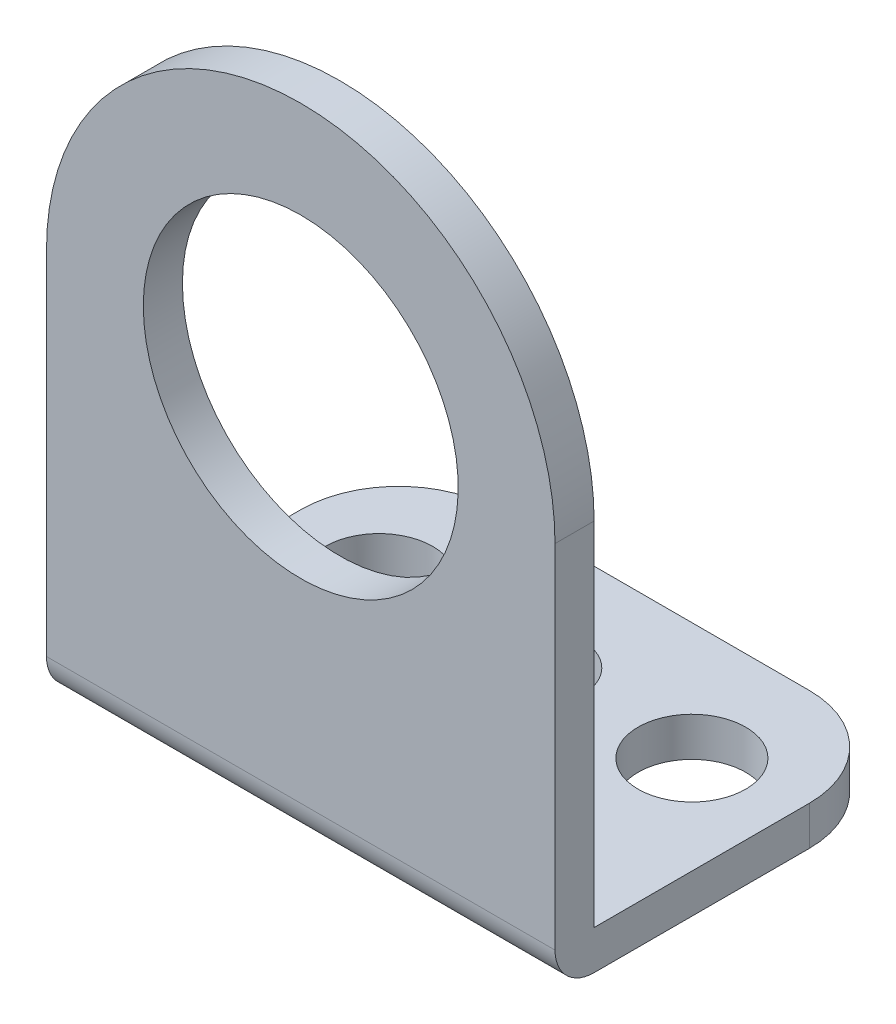
from build123d import *

# Parameters (mm, degrees)
BOSS_EXTRUDE1_DEPTH = 13
SKETCH12_R          = 8.05
BOSS_EXTRUDE2_DEPTH = 2
FILLET3_R           = 2
SKETCH15_R          = 2.4
SKETCH15_R_2        = 2.75
CUT_EXTRUDE1_DEPTH  = 2
FILLET4_R           = 5
RIB1_REACH          = 43.255
SKETCH17_WALL_W     = 91.58167319
SKETCH17_WALL_H     = 2
RIB1_DRAFT_ANGLE    = 30
RIB2_REACH          = 43.255
SKETCH18_WALL_W     = 91.58167319
SKETCH18_WALL_H     = 2
RIB2_DRAFT_ANGLE    = 30


with BuildPart() as part:
    # Sketch1 → Boss-Extrude1 (new, symmetric)
    with BuildSketch(Plane(origin=(0, 0, 0), x_dir=(0, 0, -1), z_dir=(1, 0, 0))):
        Polygon((0, 7.5), (2, 7.5), (2, 2), (18, 2), (18, 0), (0, 0), align=None)
    extrude(amount=BOSS_EXTRUDE1_DEPTH, both=True)

    # Sketch12 → Boss-Extrude2 (add)
    with BuildSketch(Plane(origin=(0, 0, -2), x_dir=(-1, 0, 0), z_dir=(0, 0, -1))):
        with BuildLine():
            Line((13, 20), (13, 7.5))
            Line((13, 7.5), (-13, 7.5))
            Line((-13, 7.5), (-13, 20))
            ThreePointArc((-13, 20), (0, 33), (13, 20))
        make_face()
        with Locations((0, 20)):
            Circle(SKETCH12_R, mode=Mode.SUBTRACT)
    extrude(amount=-BOSS_EXTRUDE2_DEPTH)

    # Fillet3
    fillet3_edges = [part.edges().sort_by_distance(p)[0] for p in [
        (0, 0, 0),
    ]]
    fillet(fillet3_edges, radius=FILLET3_R)

    # Sketch15 → Cut-Extrude1 (cut)
    with BuildSketch(Plane(origin=(0, 2, 0), x_dir=(1, 0, 0), z_dir=(0, 1, 0))):
        with Locations(Location((0, 12, 0), (0, 0, 270))):
            Circle(SKETCH15_R)
        with Locations(Location((8, 12, 0), (0, 0, 270))):
            Circle(SKETCH15_R_2)
        with Locations(Location((-8, 12, 0), (0, 0, 270))):
            Circle(SKETCH15_R_2)
    extrude(amount=-CUT_EXTRUDE1_DEPTH, mode=Mode.SUBTRACT)

    # Fillet4
    fillet4_edges = [part.edges().sort_by_distance(p)[0] for p in [
        (13, 1, -18),
        (-13, 1, -18),
    ]]
    fillet(fillet4_edges, radius=FILLET4_R)

    # Sketch17 wall → Rib1 (add, up to next)
    with BuildSketch(Plane(origin=(4, 4.5, -4.5), x_dir=(0, -0.707106781187, -0.707106781187), z_dir=(0, 0.707106781187, -0.707106781187)), mode=Mode.PRIVATE) as rib1_sk1:
        Rectangle(SKETCH17_WALL_W, SKETCH17_WALL_H)
    rib1_tool1 = extrude(rib1_sk1.sketch, amount=-RIB1_REACH, mode=Mode.PRIVATE) - part.part
    add(rib1_tool1.solids().sort_by_distance((4, 4.5, -4.5))[0])

    # Rib1 draft
    rib1_draft_faces = [part.faces().sort_by_distance(p)[0] for p in [
        (3, 4.146446609, -4.146446609),
        (5, 4.146446609, -4.146446609),
    ]]
    draft(rib1_draft_faces, Plane(origin=(4, 4.5, -4.5), x_dir=(0, -0.707106781187, -0.707106781187), z_dir=(0, 0.707106781187, -0.707106781187)), RIB1_DRAFT_ANGLE)

    # Sketch18 wall → Rib2 (add, up to next)
    with BuildSketch(Plane(origin=(-4, 4.5, -4.5), x_dir=(0, -0.707106781187, -0.707106781187), z_dir=(0, 0.707106781187, -0.707106781187)), mode=Mode.PRIVATE) as rib2_sk1:
        Rectangle(SKETCH18_WALL_W, SKETCH18_WALL_H)
    rib2_tool1 = extrude(rib2_sk1.sketch, amount=-RIB2_REACH, mode=Mode.PRIVATE) - part.part
    add(rib2_tool1.solids().sort_by_distance((-4, 4.5, -4.5))[0])

    # Rib2 draft
    rib2_draft_faces = [part.faces().sort_by_distance(p)[0] for p in [
        (-5, 4.146446609, -4.146446609),
        (-3, 4.146446609, -4.146446609),
    ]]
    draft(rib2_draft_faces, Plane(origin=(-4, 4.5, -4.5), x_dir=(0, -0.707106781187, -0.707106781187), z_dir=(0, 0.707106781187, -0.707106781187)), RIB2_DRAFT_ANGLE)


solid = part.part
